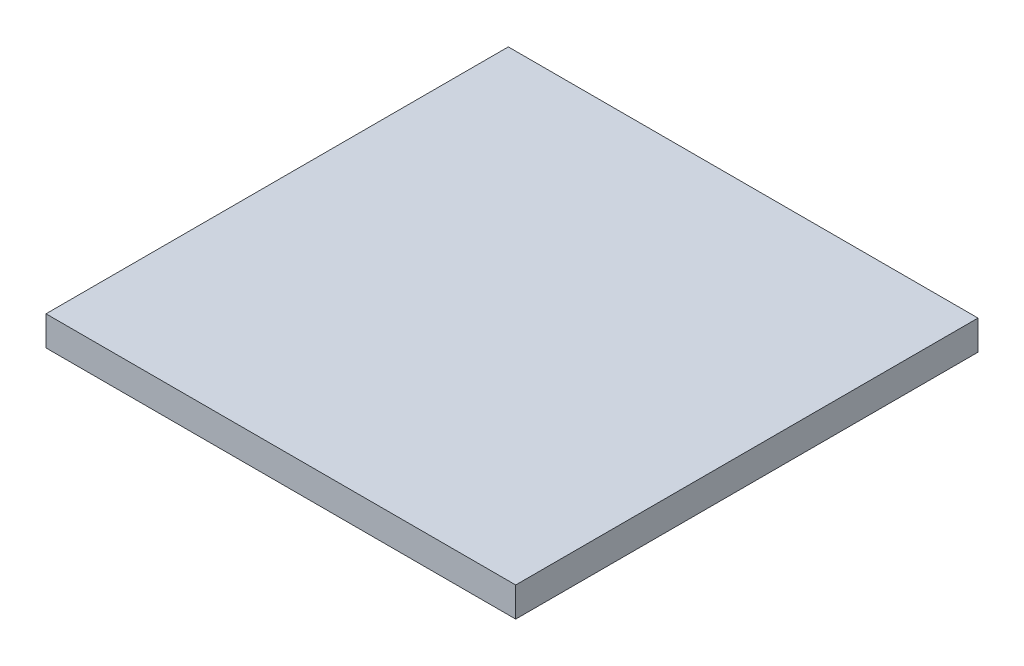
from build123d import *

# Parameters (mm, degrees)
CROQUIS1_W              = 101.6
CROQUIS1_H              = 6.4
SALIENTE_EXTRUIR1_DEPTH = 100


with BuildPart() as part:
    # Croquis1 → Saliente-Extruir1 (new body)
    with BuildSketch(Plane.XY):
        with Locations((50.8, 3.2)):
            Rectangle(CROQUIS1_W, CROQUIS1_H)
    extrude(amount=SALIENTE_EXTRUIR1_DEPTH)


solid = part.part
